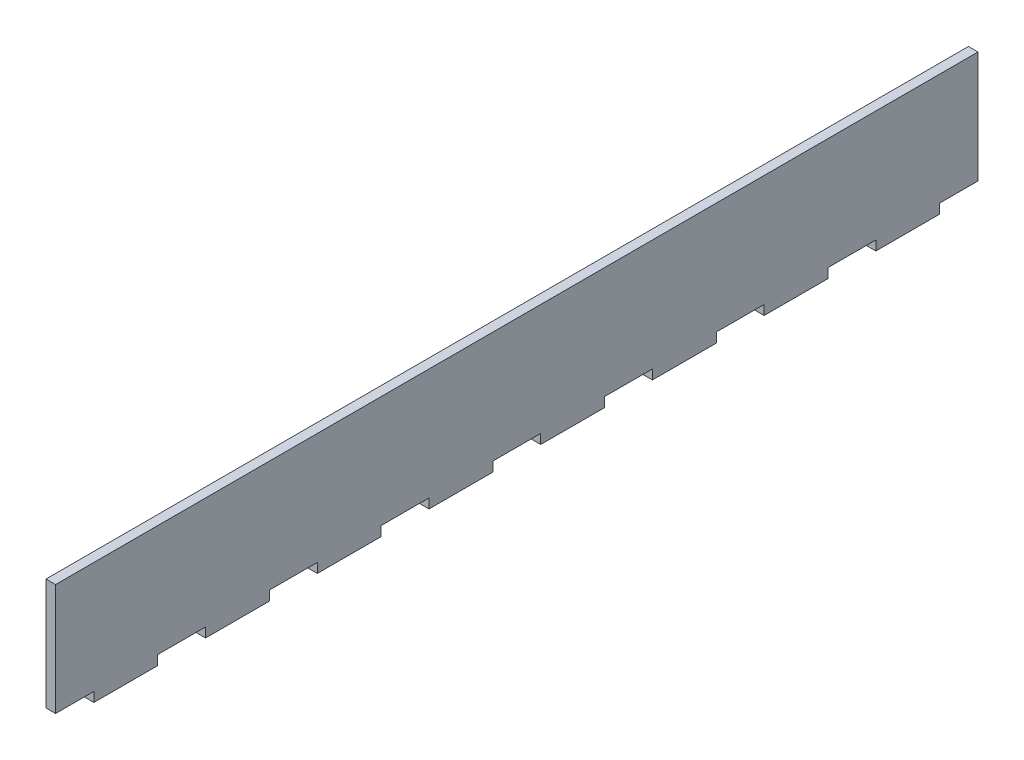
from build123d import *

# Parameters (mm, degrees)
BOSS_EXTRUDE1_DEPTH = 3


with BuildPart() as part:
    # Sketch1 → Boss-Extrude1 (new body)
    with BuildSketch(Plane(origin=(0, 0, 0), x_dir=(0, 0, -1), z_dir=(1, 0, 0))):
        Polygon((32, 0), (47, 0), (47, -3), (67, -3), (67, 0), (82, 0), (82, -3), (102, -3), (102, 0), (117, 0), (117, -3), (137, -3), (137, 0), (152, 0), (152, -3), (172, -3), (172, 0), (187, 0), (187, -3), (207, -3), (207, 0), (222, 0), (222, -3), (242, -3), (242, 0), (257, 0), (257, -3), (277, -3), (277, 0), (289, 0), (289, 35), (0, 35), (0, 0), (12, 0), (12, -3), (32, -3), align=None)
    extrude(amount=BOSS_EXTRUDE1_DEPTH)


solid = part.part
